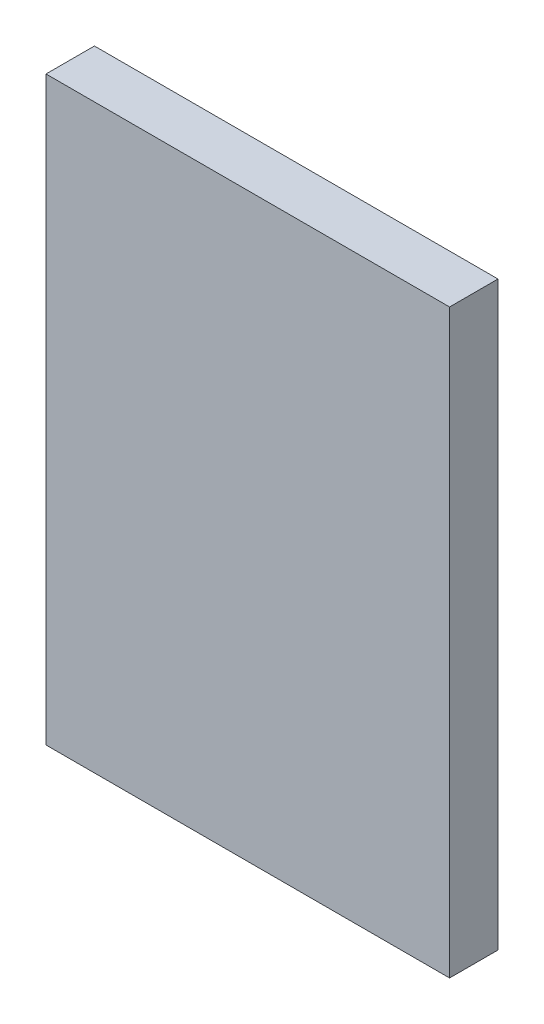
from build123d import *

# Parameters (mm, degrees)
SKETCH_1_W      = 25
SKETCH_1_H      = 36
EXTRUDE_1_DEPTH = 3


with BuildPart() as part:
    # 草图1 → 凸台-拉伸1 (new body)
    with BuildSketch(Plane.XY):
        with Locations((6.148373984, -10.479674797)):
            Rectangle(SKETCH_1_W, SKETCH_1_H)
    extrude(amount=EXTRUDE_1_DEPTH)


solid = part.part
